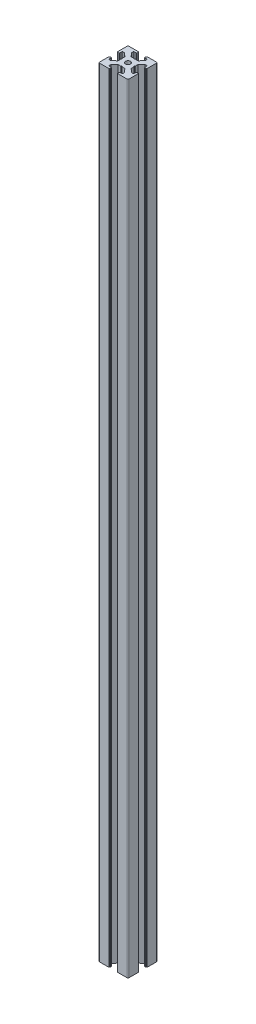
from build123d import *

# Parameters (mm, degrees)
BOSS_EXTRUDE1_DEPTH = 795
FILLET1_R           = 1
SKETCH4_R           = 2.5
CUT_EXTRUDE1_DEPTH  = 796
FILLET2_R           = 0.5


with BuildPart() as part:
    # Sketch3 → Boss-Extrude1 (new body)
    with BuildSketch(Plane(origin=(0, 0, 0), x_dir=(1, 0, 0), z_dir=(0, 1, 0))):
        with BuildLine():
            Line((11, 27.75), (11, 29.5))
            ThreePointArc((11, 29.5), (10.646446609, 29.646446609), (10.5, 30))
            Line((10.5, 30), (0, 30))
            Line((0, 30), (0, 19.5))
            ThreePointArc((0, 19.5), (0.353553391, 19.353553391), (0.5, 19))
            Line((0.5, 19), (2.25, 19))
            Line((2.25, 19), (2.25, 22))
            Line((2.25, 22), (4.5, 22))
            Line((4.5, 22), (8.25, 18.5))
            Line((8.25, 18.5), (8.25, 15.5))
            Line((8.25, 15.5), (8.75, 15))
            Line((8.75, 15), (8.25, 14.5))
            Line((8.25, 14.5), (8.25, 11.5))
            Line((8.25, 11.5), (4.5, 8))
            Line((4.5, 8), (2.25, 8))
            Line((2.25, 8), (2.25, 11))
            Line((2.25, 11), (0.5, 11))
            ThreePointArc((0.5, 11), (0.353553391, 10.646446609), (0, 10.5))
            Line((0, 10.5), (0, 0))
            Line((0, 0), (10.5, 0))
            ThreePointArc((10.5, 0), (10.646446609, 0.353553391), (11, 0.5))
            Line((11, 0.5), (11, 2.25))
            Line((11, 2.25), (8, 2.25))
            Line((8, 2.25), (8, 4.5))
            Line((8, 4.5), (11.5, 8.25))
            Line((11.5, 8.25), (14.5, 8.25))
            Line((14.5, 8.25), (15, 8.75))
            Line((15, 8.75), (15.5, 8.25))
            Line((15.5, 8.25), (18.5, 8.25))
            Line((18.5, 8.25), (22, 4.5))
            Line((22, 4.5), (22, 2.25))
            Line((22, 2.25), (19, 2.25))
            Line((19, 2.25), (19, 0.5))
            ThreePointArc((19, 0.5), (19.353553391, 0.353553391), (19.5, 0))
            Line((19.5, 0), (30, 0))
            Line((30, 0), (30, 10.5))
            ThreePointArc((30, 10.5), (29.646446609, 10.646446609), (29.5, 11))
            Line((29.5, 11), (27.75, 11))
            Line((27.75, 11), (27.75, 8))
            Line((27.75, 8), (25.5, 8))
            Line((25.5, 8), (21.75, 11.5))
            Line((21.75, 11.5), (21.75, 14.5))
            Line((21.75, 14.5), (21.25, 15))
            Line((21.25, 15), (21.75, 15.5))
            Line((21.75, 15.5), (21.75, 18.5))
            Line((21.75, 18.5), (25.5, 22))
            Line((25.5, 22), (27.75, 22))
            Line((27.75, 22), (27.75, 19))
            Line((27.75, 19), (29.5, 19))
            ThreePointArc((29.5, 19), (29.646446609, 19.353553391), (30, 19.5))
            Line((30, 19.5), (30, 30))
            Line((30, 30), (19.5, 30))
            ThreePointArc((19.5, 30), (19.353553391, 29.646446609), (19, 29.5))
            Line((19, 29.5), (19, 27.75))
            Line((19, 27.75), (22, 27.75))
            Line((22, 27.75), (22, 25.5))
            Line((22, 25.5), (18.5, 21.75))
            Line((18.5, 21.75), (15.5, 21.75))
            Line((15.5, 21.75), (15, 21.25))
            Line((15, 21.25), (14.5, 21.75))
            Line((14.5, 21.75), (11.5, 21.75))
            Line((11.5, 21.75), (8, 25.5))
            Line((8, 25.5), (8, 27.75))
            Line((8, 27.75), (11, 27.75))
        make_face()
    extrude(amount=BOSS_EXTRUDE1_DEPTH)

    # Fillet1
    fillet1_edges = [part.edges().sort_by_distance(p)[0] for p in [
        (30, 397.5, 0),
        (0, 397.5, 0),
        (0, 397.5, -30),
        (30, 397.5, -30),
    ]]
    fillet(fillet1_edges, radius=FILLET1_R)

    # Sketch4 → Cut-Extrude1 (cut, through all)
    with BuildSketch(Plane(origin=(0, 795, 0), x_dir=(1, 0, 0), z_dir=(0, 1, 0))):
        with Locations((15, 15)):
            Circle(SKETCH4_R)
    extrude(amount=-CUT_EXTRUDE1_DEPTH, mode=Mode.SUBTRACT)

    # Fillet2
    fillet2_edges = [part.edges().sort_by_distance(p)[0] for p in [
        (27.75, 397.5, -19),
        (27.75, 397.5, -22),
        (21.75, 397.5, -15.5),
        (21.75, 397.5, -14.5),
        (27.75, 397.5, -8),
        (27.75, 397.5, -11),
        (19, 397.5, -2.25),
        (22, 397.5, -2.25),
        (15.5, 397.5, -8.25),
        (14.5, 397.5, -8.25),
        (8, 397.5, -2.25),
        (11, 397.5, -2.25),
        (2.25, 397.5, -11),
        (2.25, 397.5, -8),
        (8.25, 397.5, -14.5),
        (8.25, 397.5, -15.5),
        (2.25, 397.5, -22),
        (2.25, 397.5, -19),
        (11, 397.5, -27.75),
        (8, 397.5, -27.75),
        (14.5, 397.5, -21.75),
        (15.5, 397.5, -21.75),
        (22, 397.5, -27.75),
        (19, 397.5, -27.75),
    ]]
    fillet(fillet2_edges, radius=FILLET2_R)


solid = part.part
